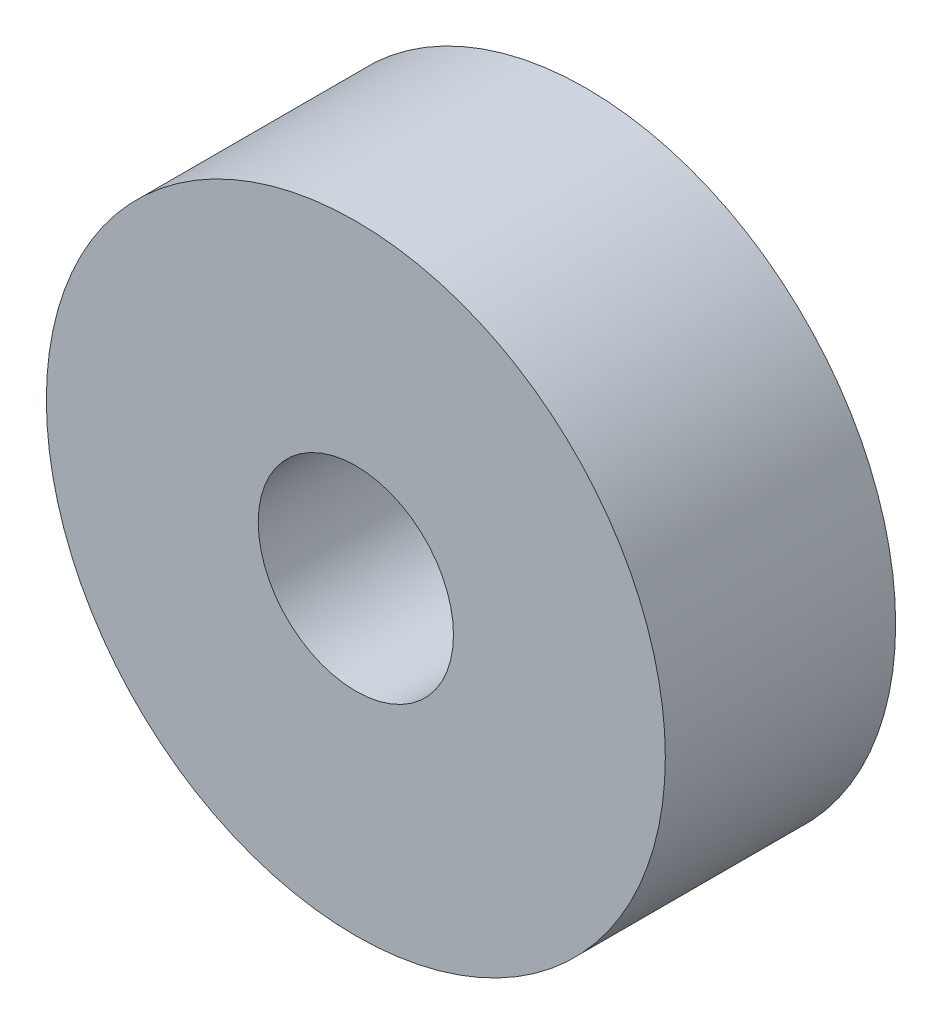
from build123d import *

# Parameters (mm, degrees)
SKETCH1_R           = 15.01775
SKETCH1_R_2         = 4.7371
BOSS_EXTRUDE1_DEPTH = 11.176


with BuildPart() as part:
    # Sketch1 → Boss-Extrude1 (new body)
    with BuildSketch(Plane.XY):
        Circle(SKETCH1_R)
        Circle(SKETCH1_R_2, mode=Mode.SUBTRACT)
    extrude(amount=BOSS_EXTRUDE1_DEPTH)


solid = part.part
